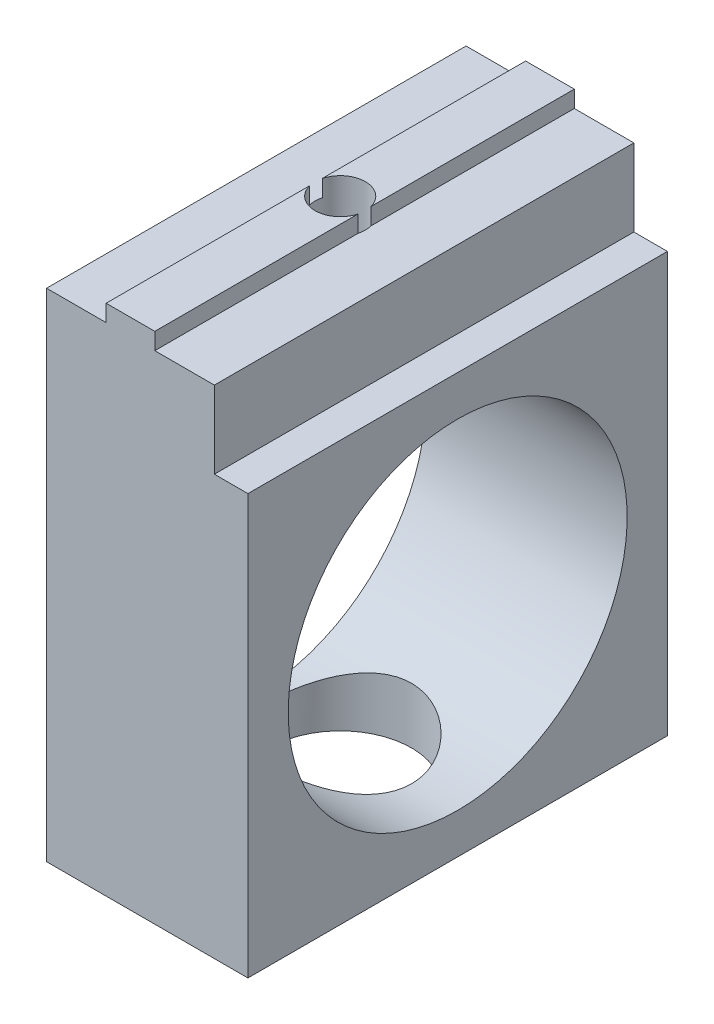
from build123d import *

# Parameters (mm, degrees)
MAKERBEAMFIX_DEPTH          = 12.5
SKETCH3_W                   = 25
SKETCH3_H                   = 25
SKETCH3_R                   = 10.1
MAKERBEAMTHREADINGTAP_DEPTH = 12
SKETCH4_R                   = 1.5
FIXINGHOLE_DEPTH            = 31.6
SKETCH5_R                   = 4.25
DRIVERHOLE_DEPTH            = 27.6000001


with BuildPart() as part:
    # Sketch1 → MakerBeamFix (new body, symmetric)
    with BuildSketch(Plane.XY):
        Polygon((-5, 0), (5, 0), (5, 7), (1.45, 7), (1.45, 8), (-1.45, 8), (-1.45, 7), (-5, 7), align=None)
    extrude(amount=MAKERBEAMFIX_DEPTH, both=True)

    # Sketch3 → MakerBeamThreadingTap (add)
    with BuildSketch(Plane.ZY.offset(5)):
        with Locations((0, -10.1)):
            Rectangle(SKETCH3_W, SKETCH3_H)
        with Locations((0, -10.1)):
            Circle(SKETCH3_R, mode=Mode.SUBTRACT)
    extrude(amount=-MAKERBEAMTHREADINGTAP_DEPTH)

    # Sketch4 → FixingHole (cut, through all)
    with BuildSketch(Plane.XZ.offset(22.6)):
        Circle(SKETCH4_R)
    extrude(amount=-FIXINGHOLE_DEPTH, mode=Mode.SUBTRACT)

    # Sketch5 → DriverHole (cut, through all)
    with BuildSketch(Plane(origin=(0, 4, 0), x_dir=(1, 0, 0), z_dir=(0, 1, 0))):
        Circle(SKETCH5_R)
    extrude(amount=-DRIVERHOLE_DEPTH, mode=Mode.SUBTRACT)


solid = part.part
